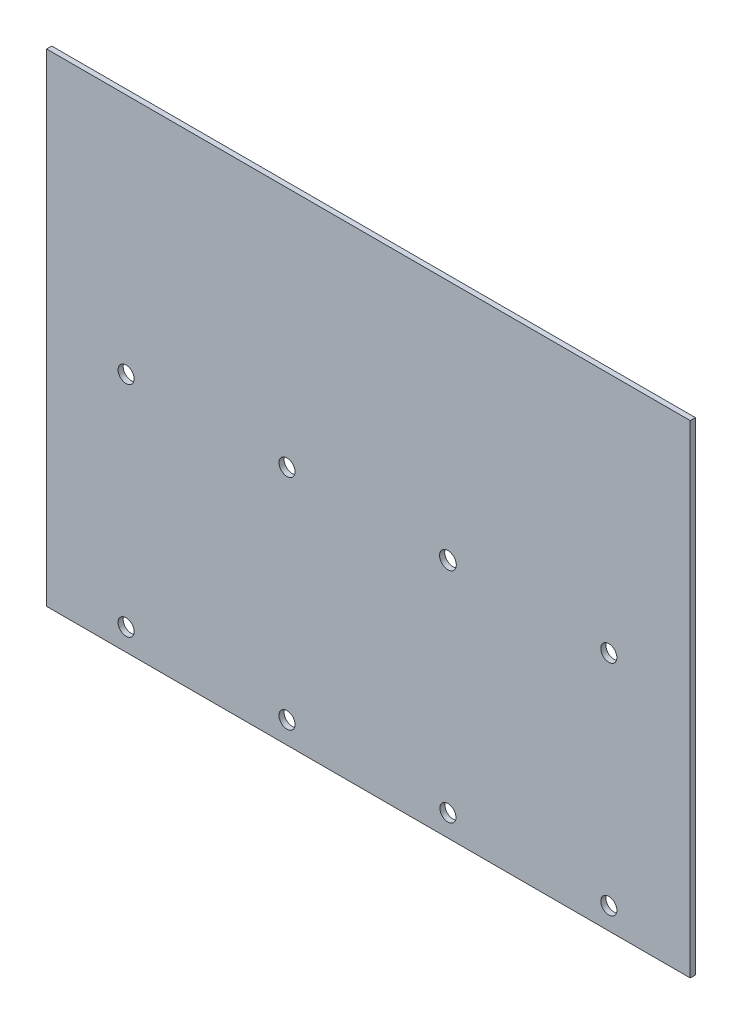
from build123d import *

# Parameters (mm, degrees)
ESQUISSE1_W             = 200
ESQUISSE1_H             = 150
BOSS_EXTRU_1_DEPTH      = 1.6
ESQUISSE2_R             = 2.5
ESQUISSE2_R_2           = 2.6
ENL_V_MAT_EXTRU_1_DEPTH = 10


with BuildPart() as part:
    # Esquisse1 → Boss.-Extru.1 (new body)
    with BuildSketch(Plane.XY):
        Rectangle(ESQUISSE1_W, ESQUISSE1_H)
    extrude(amount=BOSS_EXTRU_1_DEPTH)

    # Esquisse2 → Enlèv. mat.-Extru.1 (cut)
    with BuildSketch(Plane(origin=(0, 0, 0), x_dir=(-1, 0, 0), z_dir=(0, 0, -1))):
        with Locations((75.3, -0.196647834)):
            Circle(ESQUISSE2_R)
        with Locations((25.3, -0.196647834)):
            Circle(ESQUISSE2_R)
        with Locations((-24.7, -0.196647834)):
            Circle(ESQUISSE2_R_2)
        with Locations((-74.7, -0.196647834)):
            Circle(ESQUISSE2_R)
        with Locations((75.3, -68.196647834)):
            Circle(ESQUISSE2_R)
        with Locations((25.3, -68.196647834)):
            Circle(ESQUISSE2_R)
        with Locations((-24.7, -68.196647834)):
            Circle(ESQUISSE2_R)
        with Locations((-74.7, -68.196647834)):
            Circle(ESQUISSE2_R)
    extrude(amount=-ENL_V_MAT_EXTRU_1_DEPTH, mode=Mode.SUBTRACT)


solid = part.part
